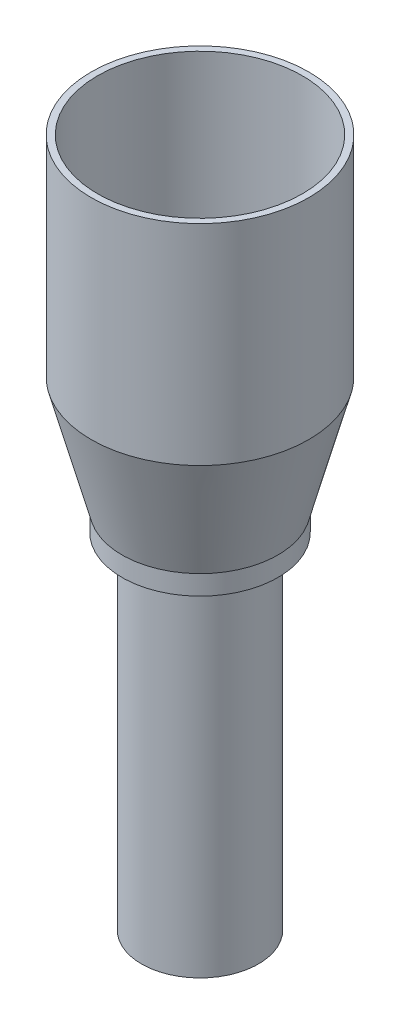
from build123d import *


with BuildPart() as part:
    # Esquisse2 → Révolution1 (revolve)
    with BuildSketch(Plane.XY):
        Polygon((9, -31.721029288), (8, -31.721029288), (8, -31.640944035), (8, 22.278970712), (15.75, 42.167419354), (15.75, 74.278970712), (16.75, 74.278970712), (16.75, 42.035980057), (12, 24.278970712), (12, 21.278970712), (9, 21.278970712), align=None)
    revolve(axis=Axis((0, 49.363390201, 0), (0, -1, 0)))


solid = part.part
